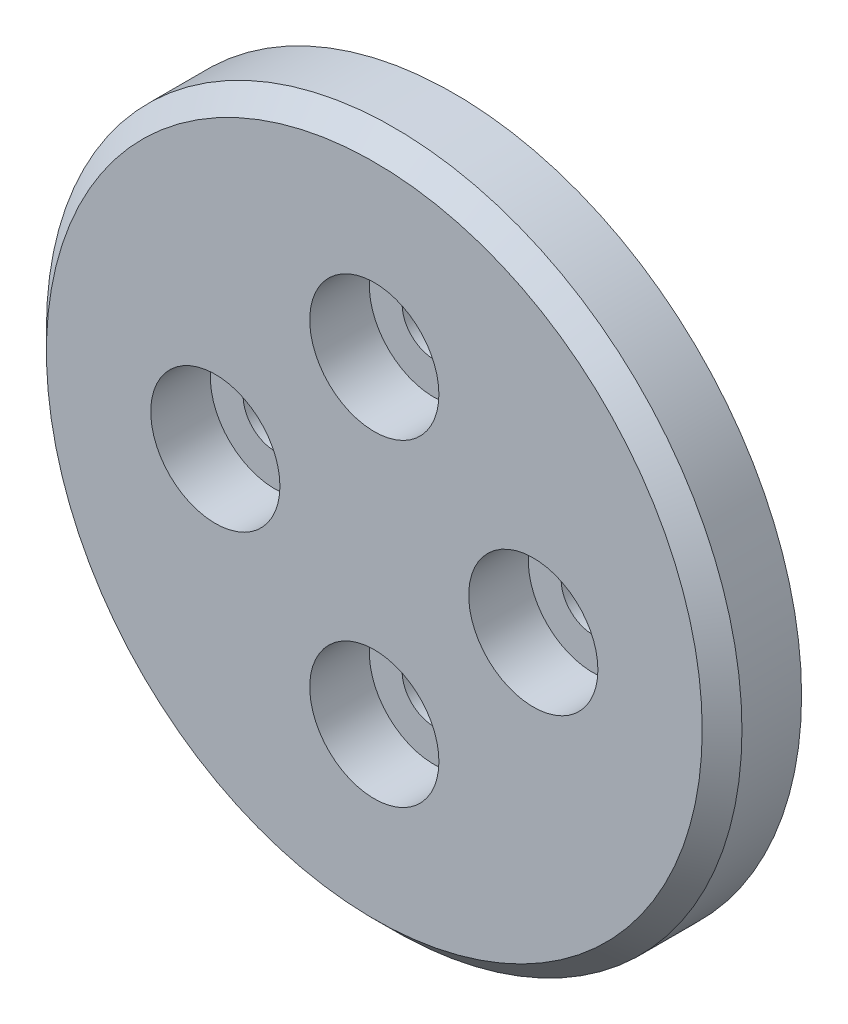
from build123d import *

# Parameters (mm, degrees)
SKETCH1_R                      = 17.5
BOSS_EXTRUDE1_DEPTH            = 4
SKETCH2_R                      = 12
BOSS_EXTRUDE2_DEPTH            = 0.6
CBORE_FOR_M3_SHCS1_D           = 3.2
CBORE_FOR_M3_SHCS1_CBORE_D     = 6.5
CBORE_FOR_M3_SHCS1_CBORE_DEPTH = 3
CHAMFER1_SIZE                  = 1


with BuildPart() as part:
    # Sketch1 → Boss-Extrude1 (new body)
    with BuildSketch(Plane.XY):
        Circle(SKETCH1_R)
    extrude(amount=BOSS_EXTRUDE1_DEPTH)

    # Sketch2 → Boss-Extrude2 (add)
    with BuildSketch(Plane(origin=(0, 0, 0), x_dir=(-1, 0, 0), z_dir=(0, 0, -1))):
        Circle(SKETCH2_R)
    extrude(amount=BOSS_EXTRUDE2_DEPTH)

    # CBORE for M3 SHCS1 (through all)
    with Locations(Plane.XY.offset(4)):
        with Locations((0, 8), (8, 0), (0, -8), (-8, 0)):
            CounterBoreHole(CBORE_FOR_M3_SHCS1_D / 2, CBORE_FOR_M3_SHCS1_CBORE_D / 2, CBORE_FOR_M3_SHCS1_CBORE_DEPTH)

    # Chamfer1
    chamfer1_edges = [part.edges().sort_by_distance(p)[0] for p in [
        (-17.5, 0, 4),
    ]]
    chamfer(chamfer1_edges, length=CHAMFER1_SIZE)


solid = part.part
